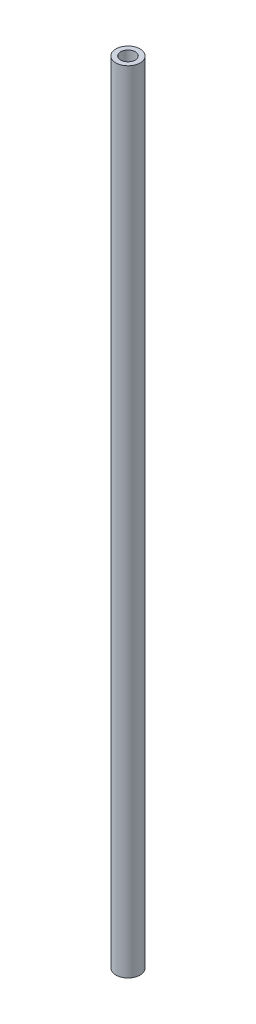
from build123d import *

# Parameters (mm, degrees)
SKETCH2_R           = 2.5
SKETCH2_R_2         = 1.5
BOSS_EXTRUDE3_DEPTH = 81.5


with BuildPart() as part:
    # Sketch2 → Boss-Extrude3 (new body, symmetric)
    with BuildSketch(Plane(origin=(0, 0, 0), x_dir=(1, 0, 0), z_dir=(0, 1, 0))):
        Circle(SKETCH2_R)
        Circle(SKETCH2_R_2, mode=Mode.SUBTRACT)
    extrude(amount=BOSS_EXTRUDE3_DEPTH, both=True)


solid = part.part
